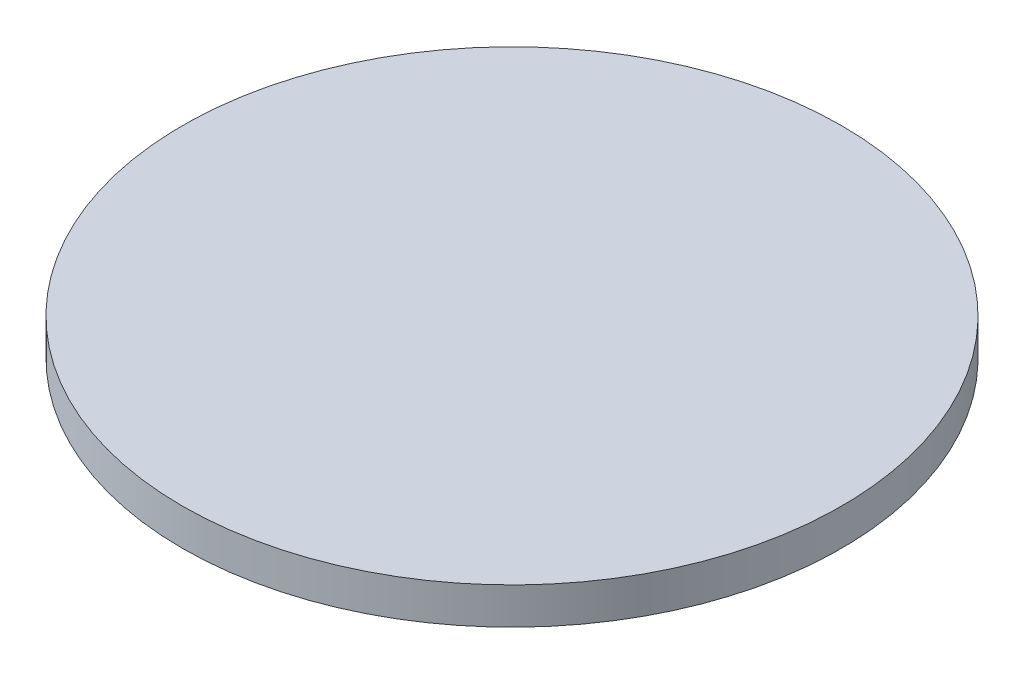
from build123d import *

# Parameters (mm, degrees)
SKETCH1_R           = 457.2
BOSS_EXTRUDE1_DEPTH = 50.8


with BuildPart() as part:
    # Sketch1 → Boss-Extrude1 (new body)
    with BuildSketch(Plane(origin=(0, 0, 0), x_dir=(1, 0, 0), z_dir=(0, 1, 0))):
        Circle(SKETCH1_R)
    extrude(amount=BOSS_EXTRUDE1_DEPTH)


solid = part.part
